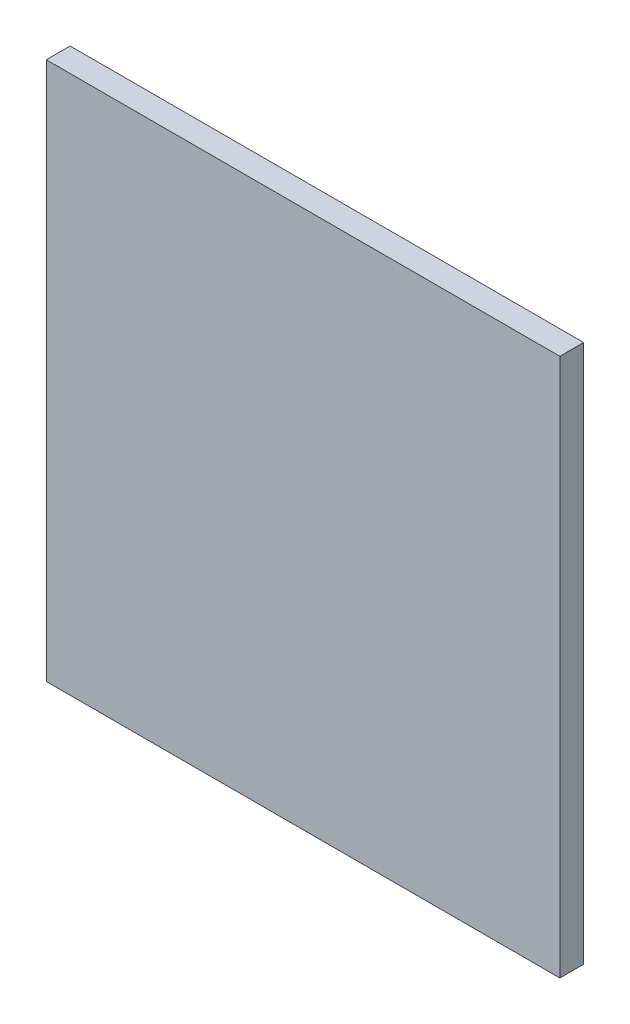
from build123d import *

# Parameters (mm, degrees)
SKETCH1_W           = 16.415
SKETCH1_H           = 17.20875
BOSS_EXTRUDE1_DEPTH = 0.762


with BuildPart() as part:
    # Sketch1 → Boss-Extrude1 (new body)
    with BuildSketch(Plane.XY):
        with Locations((-73.66, -84.3122297)):
            Rectangle(SKETCH1_W, SKETCH1_H)
    extrude(amount=BOSS_EXTRUDE1_DEPTH)


solid = part.part
